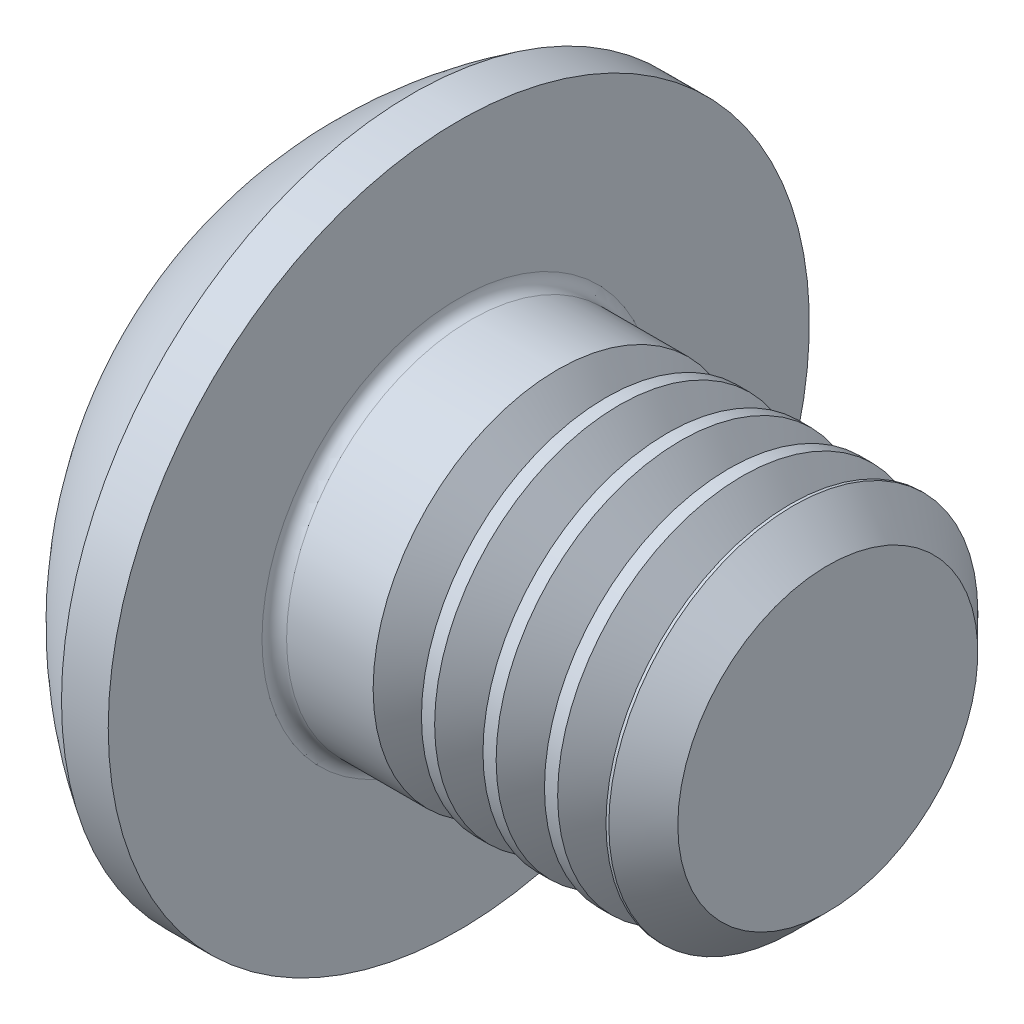
from build123d import *

# Parameters (mm, degrees)
FILLET1_R       = 0.1
HEX_2_DEPTH     = 1.04
THDSCHPAT_COUNT = 4
THDSCHPAT_PITCH = 0.5


with BuildPart() as part:
    # BodySke → BaseBody (revolve)
    with BuildSketch(Plane.XY):
        with BuildLine():
            Line((4.65, 0), (4.65, 1.2195))
            Line((4.65, 1.2195), (4.3695, 1.5))
            Line((4.3695, 1.5), (1.65, 1.5))
            Line((1.65, 1.5), (1.65, 2.85))
            Line((1.65, 2.85), (1.27, 2.85))
            ThreePointArc((1.27, 2.85), (0.53140404, 2.229827628), (0, 1.425))
            Line((0, 1.425), (0, 0))
            Line((0, 0), (4.65, 0))
        make_face()
    revolve(axis=Axis((0, 0, 0), (1, 0, 0)))

    # Fillet1
    fillet1_edges = [part.edges().sort_by_distance(p)[0] for p in [
        (1.65, -1.5, 0),
    ]]
    fillet(fillet1_edges, radius=FILLET1_R)

    # Sketch2 → PreBroach (revolve, cut)
    with BuildSketch(Plane.XY):
        Polygon((0, 1), (1.04, 1), (1.617350269, 0), (0, 0), align=None)
    revolve(axis=Axis((0, 0, 0), (1, 0, 0)), mode=Mode.SUBTRACT)

    # Sketch3 → Hex 2 (cut)
    with BuildSketch(Plane(origin=(0, 0, 0), x_dir=(0, 0, -1), z_dir=(1, 0, 0))):
        Polygon((-1, -0.577350269), (-1, 0.577350269), (0, 1.154700538), (1, 0.577350269), (1, -0.577350269), (0, -1.154700538), align=None)
    extrude(amount=HEX_2_DEPTH, mode=Mode.SUBTRACT)

    # ThdSchSke → ThreadSchematic (revolve, cut)
    with BuildSketch(Plane.XY):
        Polygon((2.65, -1.2195), (2.453591786, -1.5), (2.453591786, -1.875), (2.846408214, -1.875), (2.846408214, -1.5), align=None)
    threadschematic = revolve(axis=Axis((-3.175, 0, 0), (1, 0, 0)), mode=Mode.SUBTRACT)

    # ThdSchPat: ThreadSchematic ×4
    with Locations(*[(i * THDSCHPAT_PITCH, 0, 0) for i in range(1, THDSCHPAT_COUNT)]):
        add(threadschematic, mode=Mode.SUBTRACT)


solid = part.part
